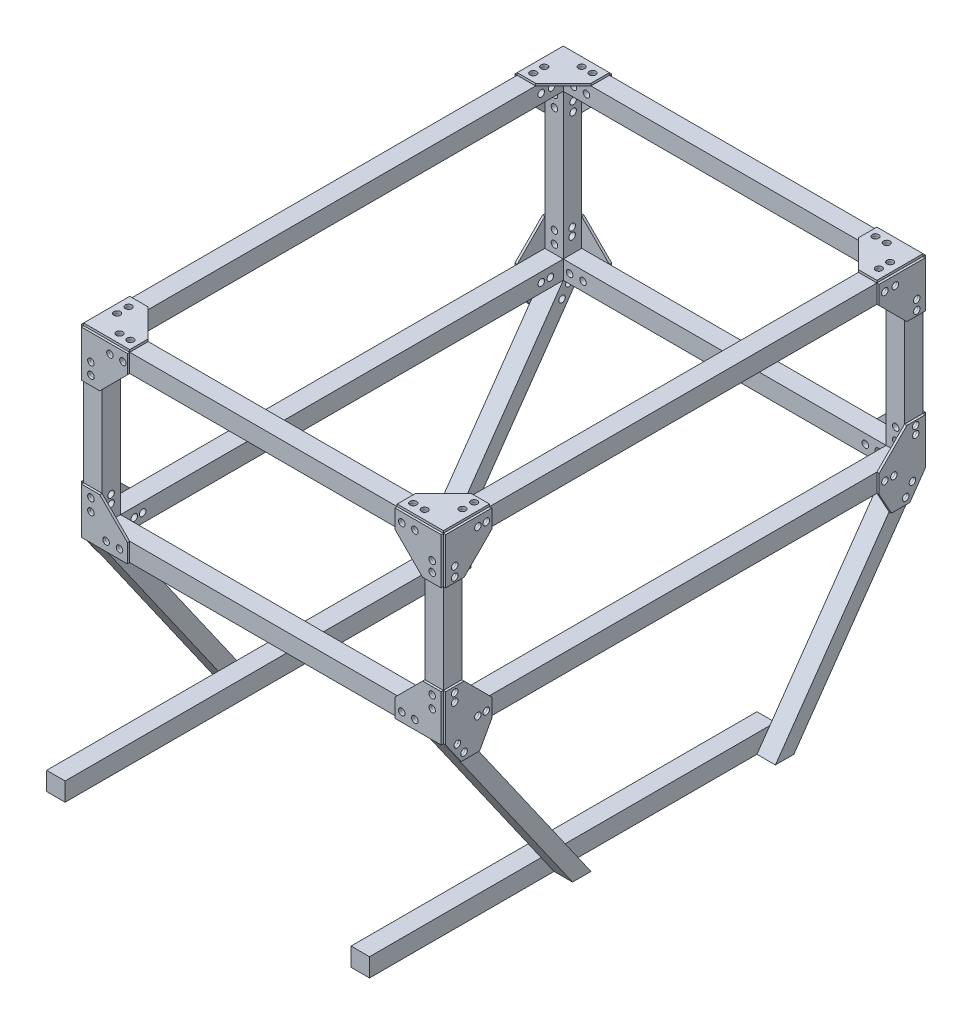
from build123d import *

# Parameters (mm, degrees)
SKETCH1_W                  = 12.7
SKETCH1_H                  = 12.7
BOSS_EXTRUDE1_DEPTH        = 304.8
SKETCH3_W                  = 12.7
SKETCH3_H                  = 12.7
BOSS_EXTRUDE2_DEPTH        = 222.25
BOSS_EXTRUDE2_DEPTH_BACK   = 12.7
BOSS_EXTRUDE2_2_DEPTH      = 222.25
BOSS_EXTRUDE2_2_DEPTH_BACK = 12.7
SKETCH5_W                  = 12.7
SKETCH5_H                  = 12.7
BOSS_EXTRUDE3_DEPTH        = 317.5
BOSS_EXTRUDE3_DEPTH_BACK   = 12.7
SKETCH6_W                  = 12.7
SKETCH6_H                  = 12.7
BOSS_EXTRUDE4_DEPTH        = 100
BOSS_EXTRUDE4_2_DEPTH      = 100
BOSS_EXTRUDE4_3_DEPTH      = 100
BOSS_EXTRUDE4_4_DEPTH      = 100
SKETCH8_W                  = 12.7
SKETCH8_H                  = 12.7
BOSS_EXTRUDE6_DEPTH        = 247.65
SKETCH9_W                  = 12.7
SKETCH9_H                  = 12.7
BOSS_EXTRUDE8_DEPTH        = 317.5
BOSS_EXTRUDE8_2_DEPTH      = 317.5
SKETCH10_W                 = 12.7
SKETCH10_H                 = 12.7
BOSS_EXTRUDE9_DEPTH        = 222.25
BOSS_EXTRUDE11_DEPTH       = 12.7
BOSS_EXTRUDE12_DEPTH       = 12.7
BOSS_EXTRUDE13_DEPTH       = 12.7
BOSS_EXTRUDE13_2_DEPTH     = 12.7
SKETCH15_W                 = 279.4
SKETCH15_H                 = 12.7
BOSS_EXTRUDE15_DEPTH       = 12.7
SKETCH16_W                 = 279.4
SKETCH16_H                 = 12.7
BOSS_EXTRUDE16_DEPTH       = 12.7
SKETCH17_R                 = 2.25
BOSS_EXTRUDE17_DEPTH       = 1.5875
BOSS_EXTRUDE17_2_DEPTH     = 1.5875
BOSS_EXTRUDE17_3_DEPTH     = 1.5875
BOSS_EXTRUDE17_4_DEPTH     = 1.5875
BOSS_EXTRUDE18_DEPTH       = 1.5875
BOSS_EXTRUDE18_2_DEPTH     = 1.5875
BOSS_EXTRUDE18_3_DEPTH     = 1.5875
BOSS_EXTRUDE18_4_DEPTH     = 1.5875
BOSS_EXTRUDE19_DEPTH       = 1.5875
BOSS_EXTRUDE19_2_DEPTH     = 1.5875
BOSS_EXTRUDE19_3_DEPTH     = 1.5875
BOSS_EXTRUDE19_4_DEPTH     = 1.5875
SKETCH20_R                 = 2.25
BOSS_EXTRUDE20_DEPTH       = 1.5875
BOSS_EXTRUDE20_2_DEPTH     = 1.5875
BOSS_EXTRUDE20_3_DEPTH     = 1.5875
BOSS_EXTRUDE20_4_DEPTH     = 1.5875
SKETCH17_4_R               = 2.25
CUT_EXTRUDE1_DEPTH         = 250.2375
SKETCH17_6_R               = 2.25
CUT_EXTRUDE4_DEPTH         = 250.2375
SKETCH17_7_R               = 2.25
CUT_EXTRUDE5_DEPTH         = 250.2375
SKETCH20_2_R               = 2.25
CUT_EXTRUDE6_DEPTH         = 369.326357353
SKETCH23_R                 = 2.25
BOSS_EXTRUDE22_DEPTH       = 1.5875
BOSS_EXTRUDE22_2_DEPTH     = 1.5875
BOSS_EXTRUDE22_3_DEPTH     = 1.5875
BOSS_EXTRUDE22_4_DEPTH     = 1.5875
SKETCH23_3_R               = 2.25
CUT_EXTRUDE7_DEPTH         = 12.7
SKETCH23_4_R               = 2.25
CUT_EXTRUDE8_DEPTH         = 12.7


with BuildPart() as part:
    # Sketch1 → Boss-Extrude1 (new body)
    with BuildSketch(Plane.XY):
        with Locations((6.35, 6.35)):
            Rectangle(SKETCH1_W, SKETCH1_H)
    extrude(amount=BOSS_EXTRUDE1_DEPTH)


with BuildPart() as body_2:
    # Sketch3 → Boss-Extrude2 (new body, two sides)
    with BuildSketch(Plane(origin=(12.7, 0, 0), x_dir=(0, 0, -1), z_dir=(1, 0, 0))) as boss_extrude2_sk:
        with Locations((6.35, 6.35)):
            Rectangle(SKETCH3_W, SKETCH3_H)
    extrude(amount=BOSS_EXTRUDE2_DEPTH)
    extrude(boss_extrude2_sk.sketch, amount=-BOSS_EXTRUDE2_DEPTH_BACK)


with BuildPart() as body_3:
    # Sketch3 → Boss-Extrude2 2 (new body, two sides)
    with BuildSketch(Plane(origin=(12.7, 0, 0), x_dir=(0, 0, -1), z_dir=(1, 0, 0))) as boss_extrude2_2_sk:
        with Locations((-311.15, 6.35)):
            Rectangle(SKETCH3_W, SKETCH3_H)
    extrude(amount=BOSS_EXTRUDE2_2_DEPTH)
    extrude(boss_extrude2_2_sk.sketch, amount=-BOSS_EXTRUDE2_2_DEPTH_BACK)


with BuildPart() as body_4:
    # Sketch5 → Boss-Extrude3 (new body, two sides)
    with BuildSketch(Plane(origin=(0, 0, 304.8), x_dir=(-1, 0, 0), z_dir=(0, 0, -1))) as boss_extrude3_sk:
        with Locations((-241.3, 6.35)):
            Rectangle(SKETCH5_W, SKETCH5_H)
    extrude(amount=BOSS_EXTRUDE3_DEPTH)
    extrude(boss_extrude3_sk.sketch, amount=-BOSS_EXTRUDE3_DEPTH_BACK)


with BuildPart() as body_5:
    # Sketch6 → Boss-Extrude4 (new body)
    with BuildSketch(Plane.XZ):
        with Locations((6.35, 311.15)):
            Rectangle(SKETCH6_W, SKETCH6_H)
    extrude(amount=BOSS_EXTRUDE4_DEPTH)


with BuildPart() as body_6:
    # Sketch6 → Boss-Extrude4 2 (new body)
    with BuildSketch(Plane.XZ):
        with Locations((241.3, 311.15)):
            Rectangle(SKETCH6_W, SKETCH6_H)
    extrude(amount=BOSS_EXTRUDE4_2_DEPTH)


with BuildPart() as body_7:
    # Sketch6 → Boss-Extrude4 3 (new body)
    with BuildSketch(Plane.XZ):
        with Locations((6.35, -6.35)):
            Rectangle(SKETCH6_W, SKETCH6_H)
    extrude(amount=BOSS_EXTRUDE4_3_DEPTH)


with BuildPart() as body_8:
    # Sketch6 → Boss-Extrude4 4 (new body)
    with BuildSketch(Plane.XZ):
        with Locations((241.3, -6.35)):
            Rectangle(SKETCH6_W, SKETCH6_H)
    extrude(amount=BOSS_EXTRUDE4_4_DEPTH)


with BuildPart() as body_9:
    # Sketch8 → Boss-Extrude6 (new body)
    with BuildSketch(Plane(origin=(247.65, 0, 0), x_dir=(0, 0, -1), z_dir=(1, 0, 0))):
        with Locations((-311.15, -106.35)):
            Rectangle(SKETCH8_W, SKETCH8_H)
    extrude(amount=-BOSS_EXTRUDE6_DEPTH)


with BuildPart() as body_10:
    # Sketch9 → Boss-Extrude8 (new body)
    with BuildSketch(Plane(origin=(0, 0, 304.8), x_dir=(-1, 0, 0), z_dir=(0, 0, -1))):
        with Locations((-241.3, -106.35)):
            Rectangle(SKETCH9_W, SKETCH9_H)
    extrude(amount=BOSS_EXTRUDE8_DEPTH)


with BuildPart() as body_11:
    # Sketch9 → Boss-Extrude8 2 (new body)
    with BuildSketch(Plane(origin=(0, 0, 304.8), x_dir=(-1, 0, 0), z_dir=(0, 0, -1))):
        with Locations((-6.35, -106.35)):
            Rectangle(SKETCH9_W, SKETCH9_H)
    extrude(amount=BOSS_EXTRUDE8_2_DEPTH)


with BuildPart() as body_12:
    # Sketch10 → Boss-Extrude9 (new body)
    with BuildSketch(Plane.ZY.offset(-234.95)):
        with Locations((-6.35, -106.35)):
            Rectangle(SKETCH10_W, SKETCH10_H)
    extrude(amount=BOSS_EXTRUDE9_DEPTH)


with BuildPart() as body_13:
    # Sketch12 → Boss-Extrude11 (new body)
    with BuildSketch(Plane.ZY):
        Polygon((-12.7, -112.7), (0, -112.7), (88.926357353, -239.7), (76.226357353, -239.7), align=None)
    extrude(amount=-BOSS_EXTRUDE11_DEPTH)


with BuildPart() as body_14:
    # Sketch13 → Boss-Extrude12 (new body)
    with BuildSketch(Plane.ZY):
        Polygon((317.5, -112.7), (304.8, -112.7), (215.873642647, -239.7), (228.573642647, -239.7), align=None)
    extrude(amount=-BOSS_EXTRUDE12_DEPTH)


with BuildPart() as body_15:
    # Sketch14 → Boss-Extrude13 (new body)
    with BuildSketch(Plane(origin=(247.65, 0, 0), x_dir=(0, 0, -1), z_dir=(1, 0, 0))):
        Polygon((-317.5, -112.7), (-228.573642647, -239.7), (-215.873642647, -239.7), (-304.8, -112.7), align=None)
    extrude(amount=-BOSS_EXTRUDE13_DEPTH)


with BuildPart() as body_16:
    # Sketch14 → Boss-Extrude13 2 (new body)
    with BuildSketch(Plane(origin=(247.65, 0, 0), x_dir=(0, 0, -1), z_dir=(1, 0, 0))):
        Polygon((-88.926357353, -239.7), (-76.226357353, -239.7), (12.7, -112.7), (0, -112.7), align=None)
    extrude(amount=-BOSS_EXTRUDE13_2_DEPTH)


with BuildPart() as body_17:
    # Sketch15 → Boss-Extrude15 (new body)
    with BuildSketch(Plane(origin=(12.7, 0, 0), x_dir=(0, 0, -1), z_dir=(1, 0, 0))):
        with Locations((-215.926357353, -233.35)):
            Rectangle(SKETCH15_W, SKETCH15_H)
    extrude(amount=BOSS_EXTRUDE15_DEPTH)


with BuildPart() as body_18:
    # Sketch16 → Boss-Extrude16 (new body)
    with BuildSketch(Plane.ZY.offset(-234.95)):
        with Locations((215.926357353, -233.35)):
            Rectangle(SKETCH16_W, SKETCH16_H)
    extrude(amount=BOSS_EXTRUDE16_DEPTH)


with BuildPart() as body_19:
    # Sketch17 → Boss-Extrude17 (new body)
    with BuildSketch(Plane.ZY):
        Polygon((-12.7, 12.7), (19.05, 12.7), (19.05, 0), (0, -19.05), (-12.7, -19.05), align=None)
        with Locations((-6.784745725, -15.720800994)):
            Circle(SKETCH17_R, mode=Mode.SUBTRACT)
        with Locations((-6.784745725, -9.184482746)):
            Circle(SKETCH17_R, mode=Mode.SUBTRACT)
        with Locations((15.120753266, 6.361355247)):
            Circle(SKETCH17_R, mode=Mode.SUBTRACT)
        with Locations((7.966134644, 6.361355247)):
            Circle(SKETCH17_R, mode=Mode.SUBTRACT)
    extrude(amount=BOSS_EXTRUDE17_DEPTH)


with BuildPart() as body_20:
    # Sketch17 → Boss-Extrude17 2 (new body)
    with BuildSketch(Plane.ZY):
        Polygon((317.5, 12.7), (285.75, 12.7), (285.75, 0), (304.8, -19.05), (317.5, -19.05), align=None)
        with Locations((289.5092956, 6.361355247)):
            Circle(SKETCH17_R, mode=Mode.SUBTRACT)
        with Locations((295.315666091, 6.361355247)):
            Circle(SKETCH17_R, mode=Mode.SUBTRACT)
        with Locations((311.256792347, -15.720800994)):
            Circle(SKETCH17_R, mode=Mode.SUBTRACT)
        with Locations((311.256792347, -9.184482746)):
            Circle(SKETCH17_R, mode=Mode.SUBTRACT)
    extrude(amount=BOSS_EXTRUDE17_2_DEPTH)


with BuildPart() as body_21:
    # Sketch17 → Boss-Extrude17 3 (new body)
    with BuildSketch(Plane.ZY):
        Polygon((-12.7, -112.7), (-12.7, -80.95), (0, -80.95), (19.05, -100), (19.05, -112.7), (10.671162882, -127.94), (-2.028837118, -127.94), align=None)
        with Locations((-3.838603571, -116.183590647)):
            Circle(SKETCH17_R, mode=Mode.SUBTRACT)
        with Locations((0.82993715, -123.403794366)):
            Circle(SKETCH17_R, mode=Mode.SUBTRACT)
        with Locations((-6.105589472, -84.025820636)):
            Circle(SKETCH17_R, mode=Mode.SUBTRACT)
        with Locations((-6.105589472, -89.426038711)):
            Circle(SKETCH17_R, mode=Mode.SUBTRACT)
        with Locations((15.120753266, -106.479113212)):
            Circle(SKETCH17_R, mode=Mode.SUBTRACT)
        with Locations((8.932434355, -106.479113212)):
            Circle(SKETCH17_R, mode=Mode.SUBTRACT)
    extrude(amount=BOSS_EXTRUDE17_3_DEPTH)


with BuildPart() as body_22:
    # Sketch17 → Boss-Extrude17 4 (new body)
    with BuildSketch(Plane.ZY):
        Polygon((317.5, -112.7), (317.5, -80.95), (304.8, -80.95), (285.75, -100), (285.75, -112.7), (294.128837118, -127.94), (306.828837118, -127.94), align=None)
        with Locations((311.256792347, -84.677899091)):
            Circle(SKETCH17_R, mode=Mode.SUBTRACT)
        with Locations((289.5092956, -106.479113212)):
            Circle(SKETCH17_R, mode=Mode.SUBTRACT)
        with Locations((295.315666091, -106.479113212)):
            Circle(SKETCH17_R, mode=Mode.SUBTRACT)
        with Locations((309.468904671, -116.183590647)):
            Circle(SKETCH17_R, mode=Mode.SUBTRACT)
        with Locations((304.8, -123.403794366)):
            Circle(SKETCH17_R, mode=Mode.SUBTRACT)
        with Locations((311.256792347, -90.324282695)):
            Circle(SKETCH17_R, mode=Mode.SUBTRACT)
    extrude(amount=BOSS_EXTRUDE17_4_DEPTH)


with BuildPart() as body_23:
    # Sketch18 → Boss-Extrude18 (new body)
    with BuildSketch(Plane.XY.offset(317.5)):
        Polygon((0, 12.7), (31.75, 12.7), (31.75, 0), (12.7, -19.05), (0, -19.05), align=None)
    extrude(amount=BOSS_EXTRUDE18_DEPTH)


with BuildPart() as body_24:
    # Sketch18 → Boss-Extrude18 2 (new body)
    with BuildSketch(Plane.XY.offset(317.5)):
        Polygon((247.65, 12.7), (247.65, -19.05), (234.95, -19.05), (215.9, 0), (215.9, 12.7), align=None)
    extrude(amount=BOSS_EXTRUDE18_2_DEPTH)


with BuildPart() as body_25:
    # Sketch18 → Boss-Extrude18 3 (new body)
    with BuildSketch(Plane.XY.offset(317.5)):
        Polygon((0, -112.7), (31.75, -112.7), (31.75, -100), (12.7, -80.95), (0, -80.95), align=None)
    extrude(amount=BOSS_EXTRUDE18_3_DEPTH)


with BuildPart() as body_26:
    # Sketch18 → Boss-Extrude18 4 (new body)
    with BuildSketch(Plane.XY.offset(317.5)):
        Polygon((247.65, -112.7), (247.65, -80.95), (234.95, -80.95), (215.9, -100), (215.9, -112.7), align=None)
    extrude(amount=BOSS_EXTRUDE18_4_DEPTH)


with BuildPart() as body_27:
    # Sketch19 → Boss-Extrude19 (new body)
    with BuildSketch(Plane(origin=(247.65, 0, 0), x_dir=(0, 0, -1), z_dir=(1, 0, 0))):
        Polygon((-317.5, 12.7), (-285.75, 12.7), (-285.75, 0), (-304.8, -19.05), (-317.5, -19.05), align=None)
    extrude(amount=BOSS_EXTRUDE19_DEPTH)


with BuildPart() as body_28:
    # Sketch19 → Boss-Extrude19 2 (new body)
    with BuildSketch(Plane(origin=(247.65, 0, 0), x_dir=(0, 0, -1), z_dir=(1, 0, 0))):
        Polygon((12.7, 12.7), (12.7, -19.05), (0, -19.05), (-19.05, 0), (-19.05, 12.7), align=None)
    extrude(amount=BOSS_EXTRUDE19_2_DEPTH)


with BuildPart() as body_29:
    # Sketch19 → Boss-Extrude19 3 (new body)
    with BuildSketch(Plane(origin=(247.65, 0, 0), x_dir=(0, 0, -1), z_dir=(1, 0, 0))):
        Polygon((-285.75, -112.7), (-285.75, -100), (-304.8, -80.95), (-317.5, -80.95), (-317.5, -112.7), (-306.828837118, -127.94), (-294.128837118, -127.94), align=None)
    extrude(amount=BOSS_EXTRUDE19_3_DEPTH)


with BuildPart() as body_30:
    # Sketch19 → Boss-Extrude19 4 (new body)
    with BuildSketch(Plane(origin=(247.65, 0, 0), x_dir=(0, 0, -1), z_dir=(1, 0, 0))):
        Polygon((12.7, -112.7), (12.7, -80.95), (0, -80.95), (-19.05, -100), (-19.05, -112.7), (-10.671162882, -127.94), (2.028837118, -127.94), align=None)
    extrude(amount=BOSS_EXTRUDE19_4_DEPTH)


with BuildPart() as body_31:
    # Sketch20 → Boss-Extrude20 (new body)
    with BuildSketch(Plane(origin=(0, 0, -12.7), x_dir=(-1, 0, 0), z_dir=(0, 0, -1))):
        Polygon((-247.65, 12.7), (-215.9, 12.7), (-215.9, 0), (-234.95, -20.344786023), (-247.65, -19.05), align=None)
        with Locations((-220.629320264, 6.349721933)):
            Circle(SKETCH20_R, mode=Mode.SUBTRACT)
        with Locations((-229.622707283, 6.349721933)):
            Circle(SKETCH20_R, mode=Mode.SUBTRACT)
        with Locations((-241.543603879, -12.822038256)):
            Circle(SKETCH20_R, mode=Mode.SUBTRACT)
        with Locations((-241.543603879, -5.789410119)):
            Circle(SKETCH20_R, mode=Mode.SUBTRACT)
    extrude(amount=BOSS_EXTRUDE20_DEPTH)


with BuildPart() as body_32:
    # Sketch20 → Boss-Extrude20 2 (new body)
    with BuildSketch(Plane(origin=(0, 0, -12.7), x_dir=(-1, 0, 0), z_dir=(0, 0, -1))):
        Polygon((0, 12.7), (-31.75, 12.7), (-31.75, 0), (-12.7, -19.05), (0, -19.05), align=None)
        with Locations((-28.670930573, 6.349721933)):
            Circle(SKETCH20_R, mode=Mode.SUBTRACT)
        with Locations((-19.69681109, 6.349721933)):
            Circle(SKETCH20_R, mode=Mode.SUBTRACT)
        with Locations((-6.621386862, -4.890192644)):
            Circle(SKETCH20_R, mode=Mode.SUBTRACT)
        with Locations((-6.621386862, -12.822038256)):
            Circle(SKETCH20_R, mode=Mode.SUBTRACT)
    extrude(amount=BOSS_EXTRUDE20_2_DEPTH)


with BuildPart() as body_33:
    # Sketch20 → Boss-Extrude20 3 (new body)
    with BuildSketch(Plane(origin=(0, 0, -12.7), x_dir=(-1, 0, 0), z_dir=(0, 0, -1))):
        Polygon((-247.65, -112.7), (-215.9, -112.7), (-215.9, -100), (-234.95, -80.95), (-247.65, -80.95), align=None)
        with Locations((-241.543603879, -85.852301949)):
            Circle(SKETCH20_R, mode=Mode.SUBTRACT)
        with Locations((-241.543603879, -94.169193352)):
            Circle(SKETCH20_R, mode=Mode.SUBTRACT)
        with Locations((-229.622707283, -106.487386504)):
            Circle(SKETCH20_R, mode=Mode.SUBTRACT)
        with Locations((-220.629320264, -106.487386504)):
            Circle(SKETCH20_R, mode=Mode.SUBTRACT)
    extrude(amount=BOSS_EXTRUDE20_3_DEPTH)


with BuildPart() as body_34:
    # Sketch20 → Boss-Extrude20 4 (new body)
    with BuildSketch(Plane(origin=(0, 0, -12.7), x_dir=(-1, 0, 0), z_dir=(0, 0, -1))):
        Polygon((0, -112.7), (0, -80.95), (-12.7, -80.95), (-31.75, -100), (-31.75, -112.7), align=None)
        with Locations((-6.621386862, -85.852301949)):
            Circle(SKETCH20_R, mode=Mode.SUBTRACT)
        with Locations((-6.621386862, -94.169193352)):
            Circle(SKETCH20_R, mode=Mode.SUBTRACT)
        with Locations((-26.28770183, -106.487386504)):
            Circle(SKETCH20_R, mode=Mode.SUBTRACT)
        with Locations((-17.062185059, -106.487386504)):
            Circle(SKETCH20_R, mode=Mode.SUBTRACT)
    extrude(amount=BOSS_EXTRUDE20_4_DEPTH)


with BuildPart() as cut_extrude1_tool:
    # Sketch17_4 → Cut-Extrude1 (new body, through all)
    with BuildSketch(Plane.ZY):
        with Locations((15.120753266, 6.361355247)):
            Circle(SKETCH17_4_R)
        with Locations((7.966134644, 6.361355247)):
            Circle(SKETCH17_4_R)
        with Locations((-6.784745725, -9.184482746)):
            Circle(SKETCH17_4_R)
        with Locations((-6.784745725, -15.720800994)):
            Circle(SKETCH17_4_R)
    extrude(amount=-CUT_EXTRUDE1_DEPTH)


with BuildPart() as part_1:
    add(part.part)

    # Cut-Extrude1: cut by cut_extrude1_tool
    add(cut_extrude1_tool.part, mode=Mode.SUBTRACT)


with BuildPart() as body_4_1:
    add(body_4.part)

    # Cut-Extrude1: cut by cut_extrude1_tool
    add(cut_extrude1_tool.part, mode=Mode.SUBTRACT)


with BuildPart() as body_7_1:
    add(body_7.part)

    # Cut-Extrude1: cut by cut_extrude1_tool
    add(cut_extrude1_tool.part, mode=Mode.SUBTRACT)


with BuildPart() as body_8_1:
    add(body_8.part)

    # Cut-Extrude1: cut by cut_extrude1_tool
    add(cut_extrude1_tool.part, mode=Mode.SUBTRACT)


with BuildPart() as body_28_1:
    add(body_28.part)

    # Cut-Extrude1: cut by cut_extrude1_tool
    add(cut_extrude1_tool.part, mode=Mode.SUBTRACT)


with BuildPart() as cut_extrude4_tool:
    # Sketch17_6 → Cut-Extrude4 (new body, through all)
    with BuildSketch(Plane.ZY):
        with Locations((-6.105589472, -84.025820636)):
            Circle(SKETCH17_6_R)
        with Locations((-6.105589472, -89.426038711)):
            Circle(SKETCH17_6_R)
        with Locations((8.932434355, -106.479113212)):
            Circle(SKETCH17_6_R)
        with Locations((15.120753266, -106.479113212)):
            Circle(SKETCH17_6_R)
        with Locations((-3.838603571, -116.183590647)):
            Circle(SKETCH17_6_R)
        with Locations((0.82993715, -123.403794366)):
            Circle(SKETCH17_6_R)
    extrude(amount=-CUT_EXTRUDE4_DEPTH)


with BuildPart() as body_7_2:
    add(body_7_1.part)

    # Cut-Extrude4: cut by cut_extrude4_tool
    add(cut_extrude4_tool.part, mode=Mode.SUBTRACT)


with BuildPart() as body_8_2:
    add(body_8_1.part)

    # Cut-Extrude4: cut by cut_extrude4_tool
    add(cut_extrude4_tool.part, mode=Mode.SUBTRACT)


with BuildPart() as body_10_1:
    add(body_10.part)

    # Cut-Extrude4: cut by cut_extrude4_tool
    add(cut_extrude4_tool.part, mode=Mode.SUBTRACT)


with BuildPart() as body_11_1:
    add(body_11.part)

    # Cut-Extrude4: cut by cut_extrude4_tool
    add(cut_extrude4_tool.part, mode=Mode.SUBTRACT)


with BuildPart() as body_13_1:
    add(body_13.part)

    # Cut-Extrude4: cut by cut_extrude4_tool
    add(cut_extrude4_tool.part, mode=Mode.SUBTRACT)


with BuildPart() as body_16_1:
    add(body_16.part)

    # Cut-Extrude4: cut by cut_extrude4_tool
    add(cut_extrude4_tool.part, mode=Mode.SUBTRACT)


with BuildPart() as body_30_1:
    add(body_30.part)

    # Cut-Extrude4: cut by cut_extrude4_tool
    add(cut_extrude4_tool.part, mode=Mode.SUBTRACT)


with BuildPart() as cut_extrude5_tool:
    # Sketch17_7 → Cut-Extrude5 (new body, through all)
    with BuildSketch(Plane.ZY):
        with Locations((289.5092956, 6.361355247)):
            Circle(SKETCH17_7_R)
        with Locations((295.315666091, 6.361355247)):
            Circle(SKETCH17_7_R)
        with Locations((311.256792347, -9.184482746)):
            Circle(SKETCH17_7_R)
        with Locations((311.256792347, -15.720800994)):
            Circle(SKETCH17_7_R)
        with Locations((311.256792347, -84.677899091)):
            Circle(SKETCH17_7_R)
        with Locations((311.256792347, -90.324282695)):
            Circle(SKETCH17_7_R)
        with Locations((295.315666091, -106.479113212)):
            Circle(SKETCH17_7_R)
        with Locations((289.5092956, -106.479113212)):
            Circle(SKETCH17_7_R)
        with Locations((309.468904671, -116.183590647)):
            Circle(SKETCH17_7_R)
        with Locations((304.8, -123.403794366)):
            Circle(SKETCH17_7_R)
    extrude(amount=-CUT_EXTRUDE5_DEPTH)


with BuildPart() as part_2:
    add(part_1.part)

    # Cut-Extrude5: cut by cut_extrude5_tool
    add(cut_extrude5_tool.part, mode=Mode.SUBTRACT)


with BuildPart() as body_4_2:
    add(body_4_1.part)

    # Cut-Extrude5: cut by cut_extrude5_tool
    add(cut_extrude5_tool.part, mode=Mode.SUBTRACT)


with BuildPart() as body_5_1:
    add(body_5.part)

    # Cut-Extrude5: cut by cut_extrude5_tool
    add(cut_extrude5_tool.part, mode=Mode.SUBTRACT)


with BuildPart() as body_6_1:
    add(body_6.part)

    # Cut-Extrude5: cut by cut_extrude5_tool
    add(cut_extrude5_tool.part, mode=Mode.SUBTRACT)


with BuildPart() as body_10_2:
    add(body_10_1.part)

    # Cut-Extrude5: cut by cut_extrude5_tool
    add(cut_extrude5_tool.part, mode=Mode.SUBTRACT)


with BuildPart() as body_11_2:
    add(body_11_1.part)

    # Cut-Extrude5: cut by cut_extrude5_tool
    add(cut_extrude5_tool.part, mode=Mode.SUBTRACT)


with BuildPart() as body_14_1:
    add(body_14.part)

    # Cut-Extrude5: cut by cut_extrude5_tool
    add(cut_extrude5_tool.part, mode=Mode.SUBTRACT)


with BuildPart() as body_15_1:
    add(body_15.part)

    # Cut-Extrude5: cut by cut_extrude5_tool
    add(cut_extrude5_tool.part, mode=Mode.SUBTRACT)


with BuildPart() as body_27_1:
    add(body_27.part)

    # Cut-Extrude5: cut by cut_extrude5_tool
    add(cut_extrude5_tool.part, mode=Mode.SUBTRACT)


with BuildPart() as body_29_1:
    add(body_29.part)

    # Cut-Extrude5: cut by cut_extrude5_tool
    add(cut_extrude5_tool.part, mode=Mode.SUBTRACT)


with BuildPart() as cut_extrude6_tool:
    # Sketch20_2 → Cut-Extrude6 (new body, through all)
    with BuildSketch(Plane(origin=(0, 0, -12.7), x_dir=(-1, 0, 0), z_dir=(0, 0, -1))):
        with Locations((-229.622707283, 6.349721933)):
            Circle(SKETCH20_2_R)
        with Locations((-220.629320264, 6.349721933)):
            Circle(SKETCH20_2_R)
        with Locations((-241.543603879, -5.789410119)):
            Circle(SKETCH20_2_R)
        with Locations((-241.543603879, -12.822038256)):
            Circle(SKETCH20_2_R)
        with Locations((-241.543603879, -85.852301949)):
            Circle(SKETCH20_2_R)
        with Locations((-241.543603879, -94.169193352)):
            Circle(SKETCH20_2_R)
        with Locations((-229.622707283, -106.487386504)):
            Circle(SKETCH20_2_R)
        with Locations((-220.629320264, -106.487386504)):
            Circle(SKETCH20_2_R)
        with Locations((-28.670930573, 6.349721933)):
            Circle(SKETCH20_2_R)
        with Locations((-19.69681109, 6.349721933)):
            Circle(SKETCH20_2_R)
        with Locations((-6.621386862, -4.890192644)):
            Circle(SKETCH20_2_R)
        with Locations((-6.621386862, -12.822038256)):
            Circle(SKETCH20_2_R)
        with Locations((-6.621386862, -85.852301949)):
            Circle(SKETCH20_2_R)
        with Locations((-6.621386862, -94.169193352)):
            Circle(SKETCH20_2_R)
        with Locations((-17.062185059, -106.487386504)):
            Circle(SKETCH20_2_R)
        with Locations((-26.28770183, -106.487386504)):
            Circle(SKETCH20_2_R)
    extrude(amount=-CUT_EXTRUDE6_DEPTH)


with BuildPart() as body_2_1:
    add(body_2.part)

    # Cut-Extrude6: cut by cut_extrude6_tool
    add(cut_extrude6_tool.part, mode=Mode.SUBTRACT)


with BuildPart() as body_3_1:
    add(body_3.part)

    # Cut-Extrude6: cut by cut_extrude6_tool
    add(cut_extrude6_tool.part, mode=Mode.SUBTRACT)


with BuildPart() as body_5_2:
    add(body_5_1.part)

    # Cut-Extrude6: cut by cut_extrude6_tool
    add(cut_extrude6_tool.part, mode=Mode.SUBTRACT)


with BuildPart() as body_6_2:
    add(body_6_1.part)

    # Cut-Extrude6: cut by cut_extrude6_tool
    add(cut_extrude6_tool.part, mode=Mode.SUBTRACT)


with BuildPart() as body_7_3:
    add(body_7_2.part)

    # Cut-Extrude6: cut by cut_extrude6_tool
    add(cut_extrude6_tool.part, mode=Mode.SUBTRACT)


with BuildPart() as body_8_3:
    add(body_8_2.part)

    # Cut-Extrude6: cut by cut_extrude6_tool
    add(cut_extrude6_tool.part, mode=Mode.SUBTRACT)


with BuildPart() as body_9_1:
    add(body_9.part)

    # Cut-Extrude6: cut by cut_extrude6_tool
    add(cut_extrude6_tool.part, mode=Mode.SUBTRACT)


with BuildPart() as body_12_1:
    add(body_12.part)

    # Cut-Extrude6: cut by cut_extrude6_tool
    add(cut_extrude6_tool.part, mode=Mode.SUBTRACT)


with BuildPart() as body_23_1:
    add(body_23.part)

    # Cut-Extrude6: cut by cut_extrude6_tool
    add(cut_extrude6_tool.part, mode=Mode.SUBTRACT)


with BuildPart() as body_24_1:
    add(body_24.part)

    # Cut-Extrude6: cut by cut_extrude6_tool
    add(cut_extrude6_tool.part, mode=Mode.SUBTRACT)


with BuildPart() as body_25_1:
    add(body_25.part)

    # Cut-Extrude6: cut by cut_extrude6_tool
    add(cut_extrude6_tool.part, mode=Mode.SUBTRACT)


with BuildPart() as body_26_1:
    add(body_26.part)

    # Cut-Extrude6: cut by cut_extrude6_tool
    add(cut_extrude6_tool.part, mode=Mode.SUBTRACT)


with BuildPart() as body_35:
    # Sketch23 → Boss-Extrude22 (new body)
    with BuildSketch(Plane(origin=(0, 12.7, 0), x_dir=(1, 0, 0), z_dir=(0, 1, 0))):
        Polygon((0, 12.7), (31.75, 12.7), (31.75, 0), (12.7, -19.05), (0, -19.05), align=None)
        with Locations((5.878806167, -6.275378328)):
            Circle(SKETCH23_R, mode=Mode.SUBTRACT)
        with Locations((5.878806167, -13.821098572)):
            Circle(SKETCH23_R, mode=Mode.SUBTRACT)
        with Locations((18.681790515, 6.651306352)):
            Circle(SKETCH23_R, mode=Mode.SUBTRACT)
        with Locations((26.227510759, 6.651306352)):
            Circle(SKETCH23_R, mode=Mode.SUBTRACT)
    extrude(amount=BOSS_EXTRUDE22_DEPTH)


with BuildPart() as body_36:
    # Sketch23 → Boss-Extrude22 2 (new body)
    with BuildSketch(Plane(origin=(0, 12.7, 0), x_dir=(1, 0, 0), z_dir=(0, 1, 0))):
        Polygon((247.65, 12.7), (215.9, 12.7), (215.9, 0), (234.95, -19.05), (247.65, -19.05), align=None)
        with Locations((220.94099776, 6.651306352)):
            Circle(SKETCH23_R, mode=Mode.SUBTRACT)
        with Locations((228.721844506, 6.651306352)):
            Circle(SKETCH23_R, mode=Mode.SUBTRACT)
        with Locations((241.353881934, -3.645473199)):
            Circle(SKETCH23_R, mode=Mode.SUBTRACT)
        with Locations((241.353881934, -11.396288078)):
            Circle(SKETCH23_R, mode=Mode.SUBTRACT)
    extrude(amount=BOSS_EXTRUDE22_2_DEPTH)


with BuildPart() as body_37:
    # Sketch23 → Boss-Extrude22 3 (new body)
    with BuildSketch(Plane(origin=(0, 12.7, 0), x_dir=(1, 0, 0), z_dir=(0, 1, 0))):
        Polygon((0, -317.5), (0, -285.75), (12.7, -285.75), (31.75, -304.8), (31.75, -317.5), align=None)
        with Locations((5.878806167, -292.386117773)):
            Circle(SKETCH23_R, mode=Mode.SUBTRACT)
        with Locations((5.878806167, -300.292168618)):
            Circle(SKETCH23_R, mode=Mode.SUBTRACT)
        with Locations((18.681790515, -311.50668621)):
            Circle(SKETCH23_R, mode=Mode.SUBTRACT)
        with Locations((26.227510759, -311.50668621)):
            Circle(SKETCH23_R, mode=Mode.SUBTRACT)
    extrude(amount=BOSS_EXTRUDE22_3_DEPTH)


with BuildPart() as body_38:
    # Sketch23 → Boss-Extrude22 4 (new body)
    with BuildSketch(Plane(origin=(0, 12.7, 0), x_dir=(1, 0, 0), z_dir=(0, 1, 0))):
        Polygon((247.65, -317.5), (247.65, -285.75), (234.95, -285.75), (215.9, -304.8), (215.9, -317.5), align=None)
        with Locations((241.353881934, -289.992286151)):
            Circle(SKETCH23_R, mode=Mode.SUBTRACT)
        with Locations((241.353881934, -298.027255969)):
            Circle(SKETCH23_R, mode=Mode.SUBTRACT)
        with Locations((228.721844506, -311.50668621)):
            Circle(SKETCH23_R, mode=Mode.SUBTRACT)
        with Locations((220.94099776, -311.50668621)):
            Circle(SKETCH23_R, mode=Mode.SUBTRACT)
    extrude(amount=BOSS_EXTRUDE22_4_DEPTH)


with BuildPart() as cut_extrude7_tool:
    # Sketch23_3 → Cut-Extrude7 (new body)
    with BuildSketch(Plane(origin=(0, 12.7, 0), x_dir=(1, 0, 0), z_dir=(0, 1, 0))):
        with Locations((18.681790515, 6.651306352)):
            Circle(SKETCH23_3_R)
        with Locations((26.227510759, 6.651306352)):
            Circle(SKETCH23_3_R)
        with Locations((5.878806167, -13.821098572)):
            Circle(SKETCH23_3_R)
        with Locations((220.94099776, 6.651306352)):
            Circle(SKETCH23_3_R)
        with Locations((228.721844506, 6.651306352)):
            Circle(SKETCH23_3_R)
        with Locations((241.353881934, -3.645473199)):
            Circle(SKETCH23_3_R)
        with Locations((241.353881934, -11.396288078)):
            Circle(SKETCH23_3_R)
        with Locations((5.878806167, -6.275378328)):
            Circle(SKETCH23_3_R)
    extrude(amount=-CUT_EXTRUDE7_DEPTH)


with BuildPart() as part_3:
    add(part_2.part)

    # Cut-Extrude7: cut by cut_extrude7_tool
    add(cut_extrude7_tool.part, mode=Mode.SUBTRACT)


with BuildPart() as body_2_2:
    add(body_2_1.part)

    # Cut-Extrude7: cut by cut_extrude7_tool
    add(cut_extrude7_tool.part, mode=Mode.SUBTRACT)


with BuildPart() as body_4_3:
    add(body_4_2.part)

    # Cut-Extrude7: cut by cut_extrude7_tool
    add(cut_extrude7_tool.part, mode=Mode.SUBTRACT)


with BuildPart() as cut_extrude8_tool:
    # Sketch23_4 → Cut-Extrude8 (new body)
    with BuildSketch(Plane(origin=(0, 12.7, 0), x_dir=(1, 0, 0), z_dir=(0, 1, 0))):
        with Locations((5.878806167, -292.386117773)):
            Circle(SKETCH23_4_R)
        with Locations((5.878806167, -300.292168618)):
            Circle(SKETCH23_4_R)
        with Locations((18.681790515, -311.50668621)):
            Circle(SKETCH23_4_R)
        with Locations((26.227510759, -311.50668621)):
            Circle(SKETCH23_4_R)
        with Locations((241.353881934, -289.992286151)):
            Circle(SKETCH23_4_R)
        with Locations((241.353881934, -298.027255969)):
            Circle(SKETCH23_4_R)
        with Locations((228.721844506, -311.50668621)):
            Circle(SKETCH23_4_R)
        with Locations((220.94099776, -311.50668621)):
            Circle(SKETCH23_4_R)
    extrude(amount=-CUT_EXTRUDE8_DEPTH)


with BuildPart() as part_4:
    add(part_3.part)

    # Cut-Extrude8: cut by cut_extrude8_tool
    add(cut_extrude8_tool.part, mode=Mode.SUBTRACT)


with BuildPart() as body_3_2:
    add(body_3_1.part)

    # Cut-Extrude8: cut by cut_extrude8_tool
    add(cut_extrude8_tool.part, mode=Mode.SUBTRACT)


with BuildPart() as body_4_4:
    add(body_4_3.part)

    # Cut-Extrude8: cut by cut_extrude8_tool
    add(cut_extrude8_tool.part, mode=Mode.SUBTRACT)


solid = Compound([body_17.part, body_18.part, body_19.part, body_20.part, body_21.part, body_22.part, body_31.part, body_32.part, body_33.part, body_34.part, body_28_1.part, body_13_1.part, body_16_1.part, body_30_1.part, body_10_2.part, body_11_2.part, body_14_1.part, body_15_1.part, body_27_1.part, body_29_1.part, body_5_2.part, body_6_2.part, body_7_3.part, body_8_3.part, body_9_1.part, body_12_1.part, body_23_1.part, body_24_1.part, body_25_1.part, body_26_1.part, body_35.part, body_36.part, body_37.part, body_38.part, body_2_2.part, part_4.part, body_3_2.part, body_4_4.part])
